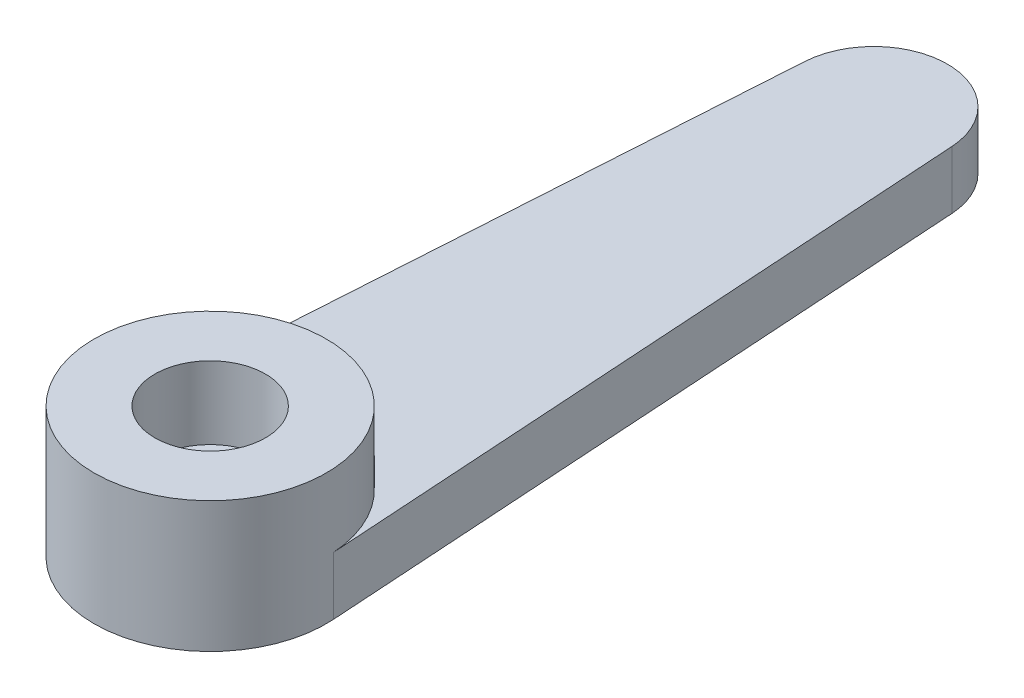
from build123d import *

# Parameters (mm, degrees)
BOSS_EXTRUDE1_DEPTH = 2
SKETCH2_R           = 4
SKETCH2_R_2         = 1.906385326
BOSS_EXTRUDE2_DEPTH = 2.5


with BuildPart() as part:
    # Sketch1 → Boss-Extrude1 (new body)
    with BuildSketch(Plane(origin=(0, 0, 0), x_dir=(1, 0, 0), z_dir=(0, 1, 0))):
        with BuildLine():
            Line((3.991833672, 0.255468066), (2.534814382, 23.022222222))
            ThreePointArc((2.534814382, 23.022222222), (0, 25.4), (-2.534814382, 23.022222222))
            Line((-2.534814382, 23.022222222), (-3.991833672, 0.255468066))
            ThreePointArc((-3.991833672, 0.255468066), (0, -4), (3.991833672, 0.255468066))
        make_face()
    extrude(amount=BOSS_EXTRUDE1_DEPTH)

    # Sketch2 → Boss-Extrude2 (add)
    with BuildSketch(Plane(origin=(0, 2, 0), x_dir=(1, 0, 0), z_dir=(0, 1, 0))):
        Circle(SKETCH2_R)
        Circle(SKETCH2_R_2, mode=Mode.SUBTRACT)
    extrude(amount=BOSS_EXTRUDE2_DEPTH)


solid = part.part
